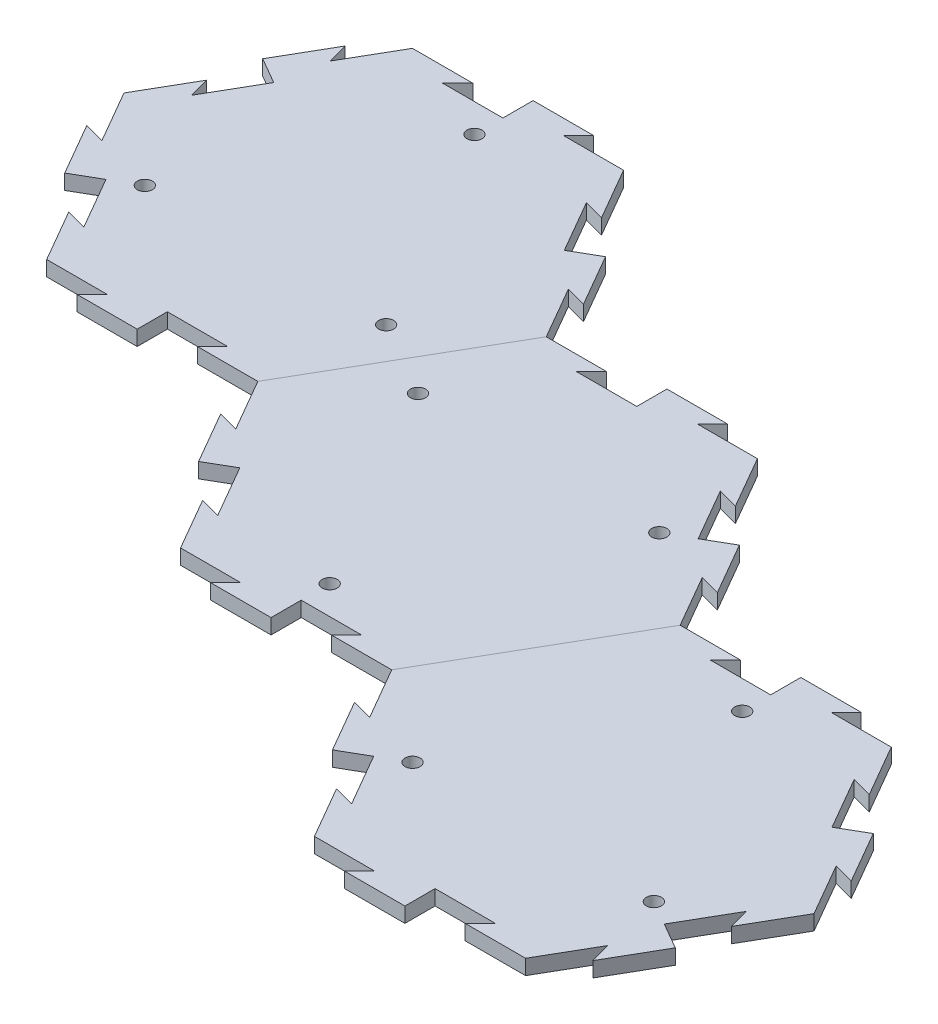
from build123d import *

# Parameters (mm, degrees)
BOSS_EXTRUDE1_DEPTH = 6.35
SKETCH9_R           = 3.175
CUT_EXTRUDE3_DEPTH  = 7.35
CIRPATTERN6_COUNT   = 3
CUT_EXTRUDE4_DEPTH  = 7.35
BOSS_EXTRUDE4_DEPTH = 6.35
CIRPATTERN7_COUNT   = 6
CUT_EXTRUDE5_DEPTH  = 7.35
BOSS_EXTRUDE5_DEPTH = 6.35
CIRPATTERN8_COUNT   = 6
CUT_EXTRUDE6_DEPTH  = 7.35
BOSS_EXTRUDE6_DEPTH = 6.35
CIRPATTERN9_COUNT   = 6


with BuildPart() as part:
    # Sketch1 → Boss-Extrude1 (new body)
    with BuildSketch(Plane(origin=(0, 0, 0), x_dir=(1, 0, 0), z_dir=(0, 1, 0))):
        Polygon((88.9, 0), (44.45, 76.989658396), (-44.45, 76.989658396), (-88.9, 0), (-44.45, -76.989658396), (44.45, -76.989658396), align=None)
    extrude(amount=-BOSS_EXTRUDE1_DEPTH)

    # Sketch9 → Cut-Extrude3 (cut, through all)
    with BuildSketch(Plane(origin=(0, 0, 0), x_dir=(1, 0, 0), z_dir=(0, 1, 0))):
        with Locations((-50.8, -29.329393675)):
            Circle(SKETCH9_R)
    cut_extrude3 = extrude(amount=-CUT_EXTRUDE3_DEPTH, mode=Mode.SUBTRACT)

    # CirPattern6: Cut-Extrude3 ×3 about axis
    cirpattern6_axis = Axis((0, 0, 0), (0, 1, 0))
    for i in range(1, CIRPATTERN6_COUNT):
        add(cut_extrude3.rotate(cirpattern6_axis, i * 360 / CIRPATTERN6_COUNT), mode=Mode.SUBTRACT)


with BuildPart() as body_2:
    # Mirror3: mirrored copy
    add(part.part.mirror(Plane(origin=(44.45, -6.35, 76.989658396), x_dir=(-0.5, 0, 0.866025404), z_dir=(0.866025404, 0, 0.5))))


with BuildPart() as part_1:
    add(part.part)

    # Sketch10 → Cut-Extrude4 (cut, through all)
    with BuildSketch(Plane(origin=(0, 0, 0), x_dir=(1, 0, 0), z_dir=(0, 1, 0))):
        Polygon((57.15, 54.99261314), (48.475738686, 57.316874454), (61.175738686, 35.319829198), (66.675, 38.494829198), align=None)
    cut_extrude4 = extrude(amount=-CUT_EXTRUDE4_DEPTH, mode=Mode.SUBTRACT)

    # Sketch11 → Boss-Extrude4 (add)
    with BuildSketch(Plane(origin=(0, 0, 0), x_dir=(1, 0, 0), z_dir=(0, 1, 0))):
        Polygon((66.675, 38.494829198), (72.174261314, 41.669829198), (84.874261314, 19.672783942), (76.2, 21.997045256), align=None)
    boss_extrude4 = extrude(amount=-BOSS_EXTRUDE4_DEPTH)

    # CirPattern7: Cut-Extrude4, Boss-Extrude4 ×6 about axis, 1 skipped
    cirpattern7_axis = Axis((0, 0, 0), (0, 1, 0))
    add([cut_extrude4.rotate(cirpattern7_axis, i * 360 / CIRPATTERN7_COUNT) for i in range(1, CIRPATTERN7_COUNT) if i not in (5,)], mode=Mode.SUBTRACT)
    add([boss_extrude4.rotate(cirpattern7_axis, i * 360 / CIRPATTERN7_COUNT) for i in range(1, CIRPATTERN7_COUNT) if i not in (5,)])


with BuildPart() as body_3:
    # Mirror4: mirrored copy
    add(body_2.part.mirror(Plane(origin=(222.25, -6.35, 76.989658396), x_dir=(-0.5, 0, 0.866025404), z_dir=(0.866025404, 0, 0.5))))

    # Sketch16 → Cut-Extrude6 (cut, through all)
    with BuildSketch(Plane(origin=(0, 0, 0), x_dir=(1, 0, 0), z_dir=(0, 1, 0))):
        Polygon((323.85, -98.986703653), (315.175738686, -96.662442339), (327.875738686, -118.659487595), (333.375, -115.484487595), align=None)
    cut_extrude6 = extrude(amount=-CUT_EXTRUDE6_DEPTH, mode=Mode.SUBTRACT)

    # Sketch17 → Boss-Extrude6 (add)
    with BuildSketch(Plane(origin=(0, 0, 0), x_dir=(1, 0, 0), z_dir=(0, 1, 0))):
        Polygon((333.375, -115.484487595), (338.874261314, -112.309487595), (351.574261314, -134.306532851), (342.9, -131.982271537), align=None)
    boss_extrude6 = extrude(amount=-BOSS_EXTRUDE6_DEPTH)

    # CirPattern9: Cut-Extrude6, Boss-Extrude6 ×6 about axis, 1 skipped
    cirpattern9_axis = Axis((266.7, 0, 153.979316793), (0, 1, 0))
    add([cut_extrude6.rotate(cirpattern9_axis, i * 360 / CIRPATTERN9_COUNT) for i in range(1, CIRPATTERN9_COUNT) if i not in (2,)], mode=Mode.SUBTRACT)
    add([boss_extrude6.rotate(cirpattern9_axis, i * 360 / CIRPATTERN9_COUNT) for i in range(1, CIRPATTERN9_COUNT) if i not in (2,)])


with BuildPart() as body_2_1:
    add(body_2.part)

    # Sketch13 → Cut-Extrude5 (cut, through all)
    with BuildSketch(Plane(origin=(0, 0, 0), x_dir=(1, 0, 0), z_dir=(0, 1, 0))):
        Polygon((190.5, -21.997045256), (181.825738686, -19.672783942), (194.525738686, -41.669829198), (200.025, -38.494829198), align=None)
    cut_extrude5 = extrude(amount=-CUT_EXTRUDE5_DEPTH, mode=Mode.SUBTRACT)

    # Sketch14 → Boss-Extrude5 (add)
    with BuildSketch(Plane(origin=(0, 0, 0), x_dir=(1, 0, 0), z_dir=(0, 1, 0))):
        Polygon((200.025, -38.494829198), (205.524261314, -35.319829198), (218.224261314, -57.316874454), (209.55, -54.99261314), align=None)
    boss_extrude5 = extrude(amount=-BOSS_EXTRUDE5_DEPTH)

    # CirPattern8: Cut-Extrude5, Boss-Extrude5 ×6 about axis, 2 skipped
    cirpattern8_axis = Axis((133.35, 0, 76.989658396), (0, 1, 0))
    add([cut_extrude5.rotate(cirpattern8_axis, i * 360 / CIRPATTERN8_COUNT) for i in range(1, CIRPATTERN8_COUNT) if i not in (2, 5)], mode=Mode.SUBTRACT)
    add([boss_extrude5.rotate(cirpattern8_axis, i * 360 / CIRPATTERN8_COUNT) for i in range(1, CIRPATTERN8_COUNT) if i not in (2, 5)])


solid = Compound([part_1.part, body_3.part, body_2_1.part])
